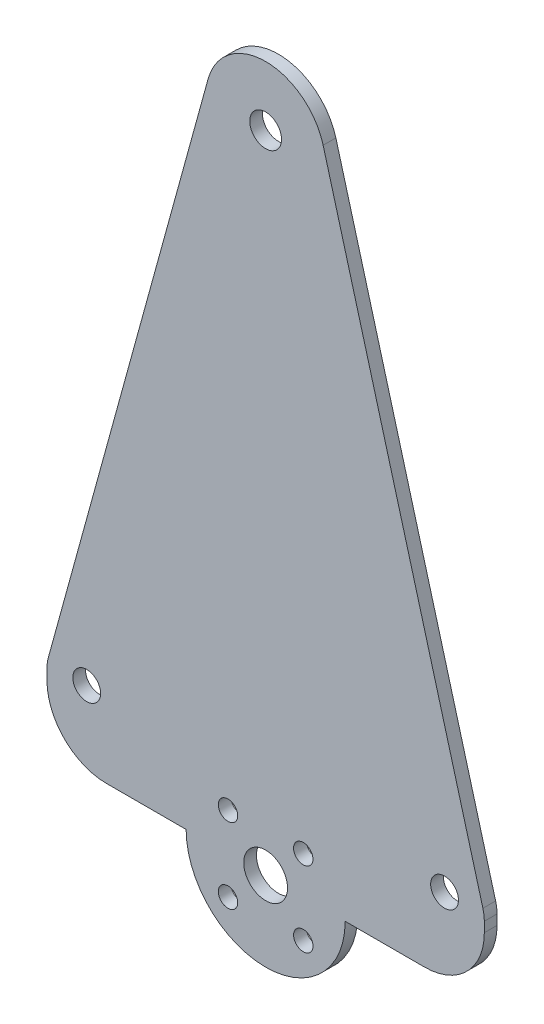
from build123d import *

# Parameters (mm, degrees)
SKETCH1_R           = 2.2225
SKETCH1_R_2         = 1.55
SKETCH1_R_3         = 2.539999998
SKETCH1_R_4         = 3.5
BOSS_EXTRUDE1_DEPTH = 2.032


with BuildPart() as part:
    # Sketch1 → Boss-Extrude1 (new body)
    with BuildSketch(Plane.XY):
        with BuildLine():
            Line((41.275, -11.969713646), (53.975, -11.969713646))
            ThreePointArc((53.975, -11.969713646), (60.710192091, -9.179905737), (63.5, -2.444713646))
            Line((63.5, -2.444713646), (63.5, -0.857213646))
            ThreePointArc((63.5, -0.857213646), (63.442919511, -0.007705539), (63.272704244, 0.826530021))
            Line((63.272704244, 0.826530021), (37.759056366, 93.603431401))
            ThreePointArc((37.759056366, 93.603431401), (28.575, 100.6028159), (19.390943634, 93.603431401))
            Line((19.390943634, 93.603431401), (-6.122704244, 0.826530021))
            ThreePointArc((-6.122704244, 0.826530021), (-6.292919511, -0.007705539), (-6.35, -0.857213646))
            Line((-6.35, -0.857213646), (-6.35, -2.444713646))
            ThreePointArc((-6.35, -2.444713646), (-3.560192091, -9.179905737), (3.175, -11.969713646))
            Line((3.175, -11.969713646), (15.875, -11.969713646))
            ThreePointArc((15.875, -11.969713646), (28.575, -24.669713646), (41.275, -11.969713646))
        make_face()
        Circle(SKETCH1_R, mode=Mode.SUBTRACT)
        with Locations((57.15, 0)):
            Circle(SKETCH1_R, mode=Mode.SUBTRACT)
        with Locations((22.56459236, -5.959306006)):
            Circle(SKETCH1_R_2, mode=Mode.SUBTRACT)
        with Locations((28.575, 91.0778159)):
            Circle(SKETCH1_R_3, mode=Mode.SUBTRACT)
        with Locations((28.575, -11.969713646)):
            Circle(SKETCH1_R_4, mode=Mode.SUBTRACT)
        with Locations((34.58540764, -17.980121287)):
            Circle(SKETCH1_R_2, mode=Mode.SUBTRACT)
        with Locations((34.58540764, -5.959306006)):
            Circle(SKETCH1_R_2, mode=Mode.SUBTRACT)
        with Locations((22.56459236, -17.980121287)):
            Circle(SKETCH1_R_2, mode=Mode.SUBTRACT)
    extrude(amount=BOSS_EXTRUDE1_DEPTH)


solid = part.part
